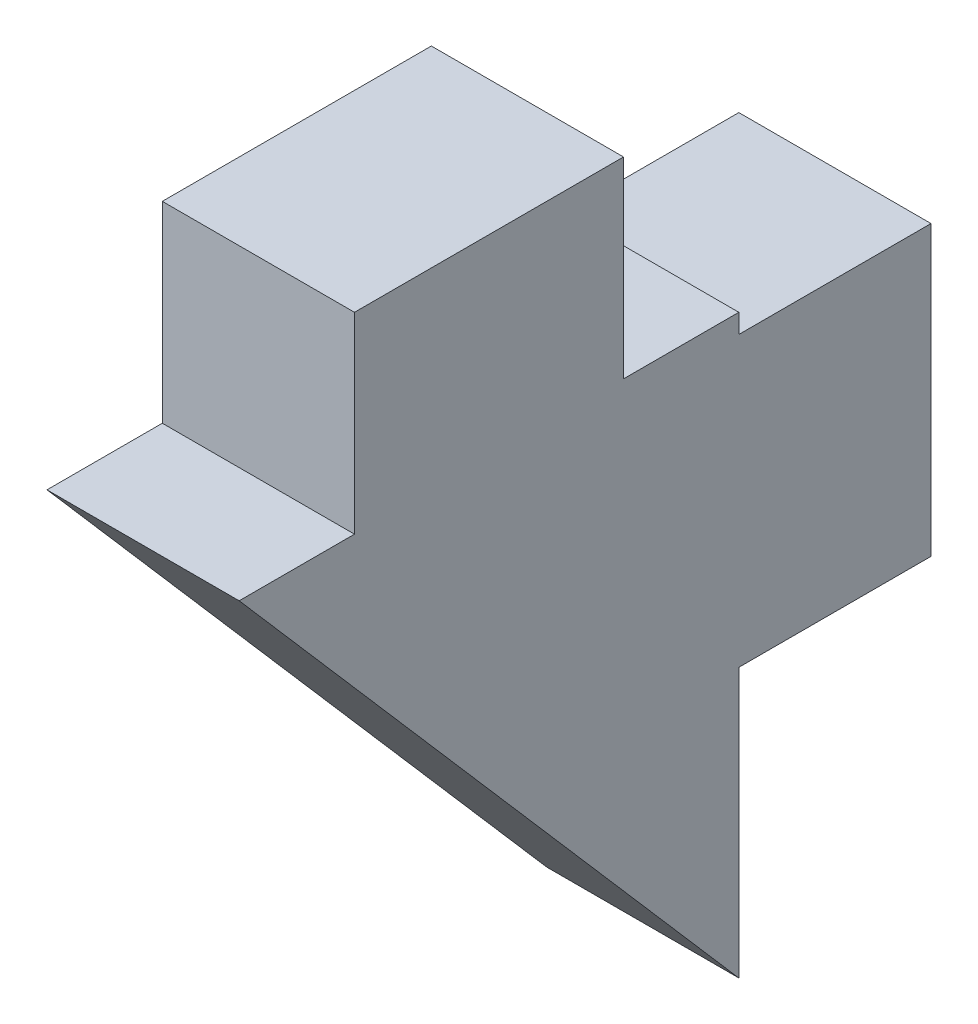
from build123d import *

# Parameters (mm, degrees)
SALIENTE_EXTRUIR2_DEPTH = 5


with BuildPart() as part:
    # Croquis1 → Saliente-Extruir2 (new body)
    with BuildSketch(Plane(origin=(0, 0, 0), x_dir=(0, 0, -1), z_dir=(1, 0, 0))):
        Polygon((0, 31.691396431), (-3, 31.691396431), (-3, 36.691396431), (-10, 36.691396431), (-10, 31.691396431), (-13, 31.691396431), (0, 16.691396431), (0, 23.691396431), (5, 23.691396431), (5, 31.191396431), (0, 31.191396431), align=None)
    extrude(amount=SALIENTE_EXTRUIR2_DEPTH)


solid = part.part
